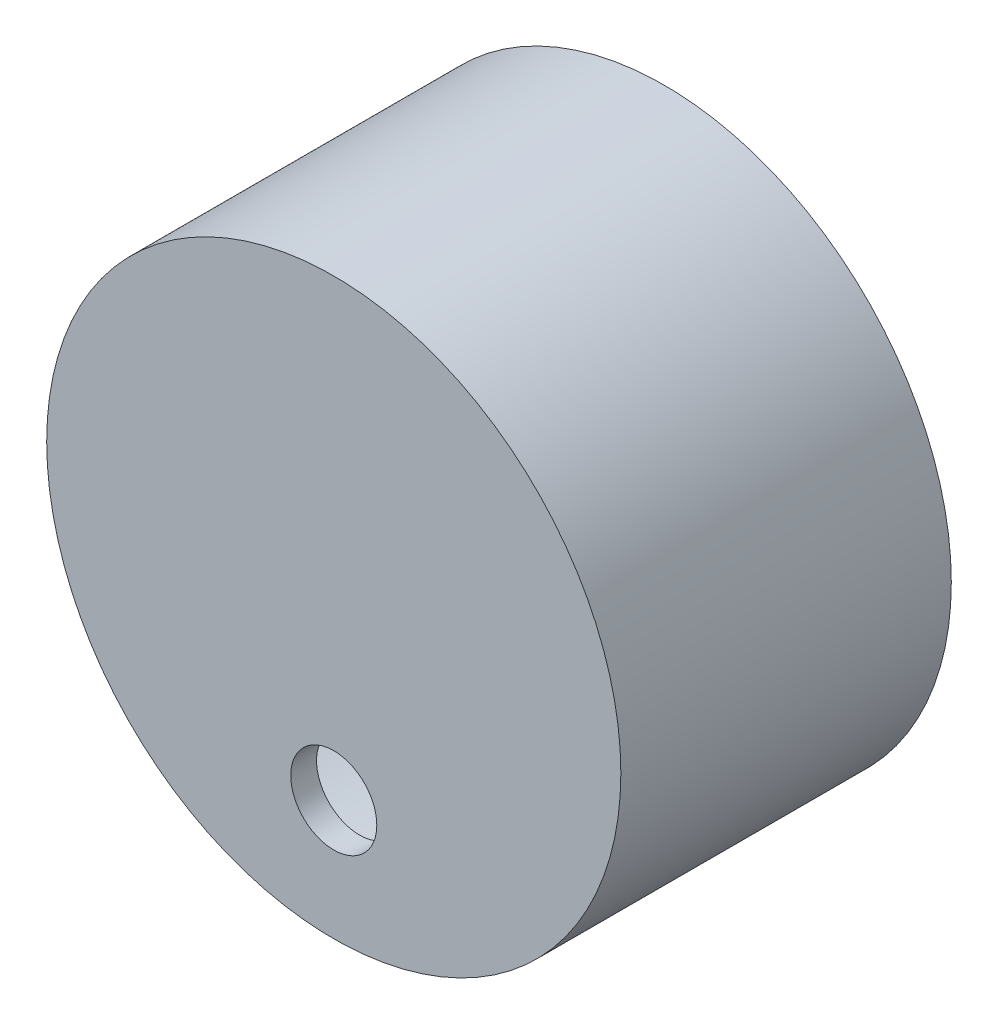
from build123d import *

# Parameters (mm, degrees)
SKETCH1_R                = 33.358351357
SKETCH1_R_2              = 30.358351357
BOSS_EXTRUDE1_DEPTH      = 25.4
BOSS_EXTRUDE1_DEPTH_BACK = 10
SKETCH2_R                = 33.358351357
SKETCH2_R_2              = 5
BOSS_EXTRUDE2_DEPTH      = 3


with BuildPart() as part:
    # Sketch1 → Boss-Extrude1 (new body, two sides)
    with BuildSketch(Plane.XY) as boss_extrude1_sk:
        with Locations((22.75, 10.5)):
            Circle(SKETCH1_R)
        with Locations((22.75, 10.5)):
            Circle(SKETCH1_R_2, mode=Mode.SUBTRACT)
    extrude(amount=BOSS_EXTRUDE1_DEPTH)
    extrude(boss_extrude1_sk.sketch, amount=-BOSS_EXTRUDE1_DEPTH_BACK)

    # Sketch2 → Boss-Extrude2 (add)
    with BuildSketch(Plane.XY.offset(25.4)):
        with Locations((22.75, 10.5)):
            Circle(SKETCH2_R)
        with Locations((22.75, -8.913617173)):
            Circle(SKETCH2_R_2, mode=Mode.SUBTRACT)
    extrude(amount=BOSS_EXTRUDE2_DEPTH)


solid = part.part
